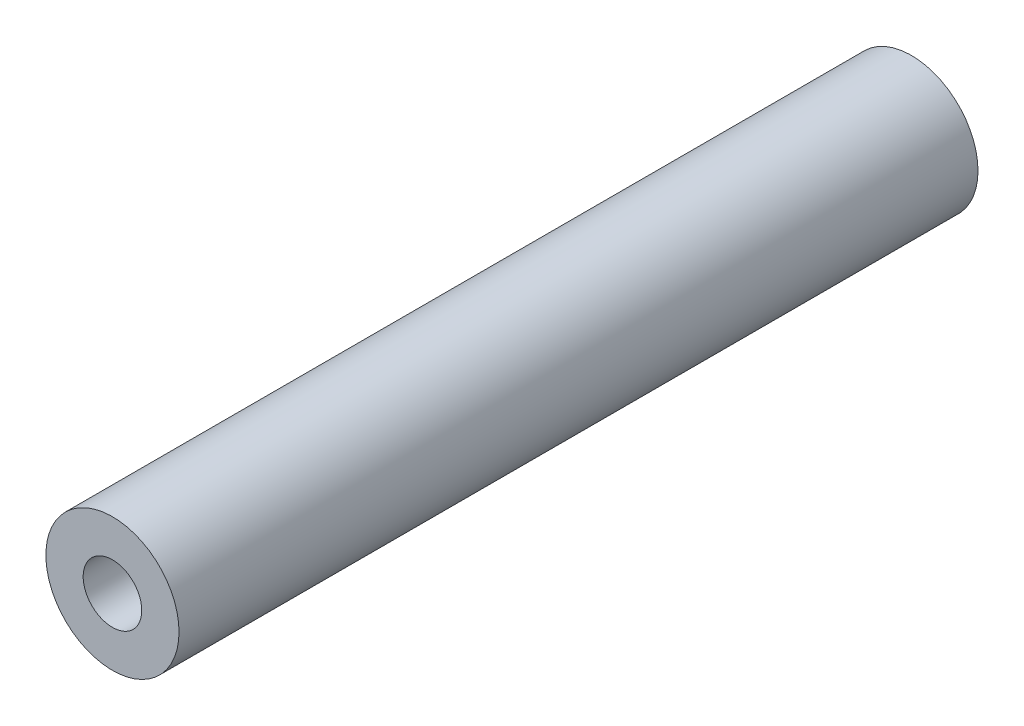
from build123d import *

# Parameters (mm, degrees)
SKETCH1_R           = 3.175
BOSS_EXTRUDE1_DEPTH = 38.1
SKETCH2_R           = 1.397
CUT_EXTRUDE1_DEPTH  = 5.08


with BuildPart() as part:
    # Sketch1 → Boss-Extrude1 (new body)
    with BuildSketch(Plane.XY):
        Circle(SKETCH1_R)
    extrude(amount=BOSS_EXTRUDE1_DEPTH)

    # Sketch2 → Cut-Extrude1 (cut)
    with BuildSketch(Plane.XY.offset(38.1)):
        Circle(SKETCH2_R)
    extrude(amount=-CUT_EXTRUDE1_DEPTH, mode=Mode.SUBTRACT)


solid = part.part
